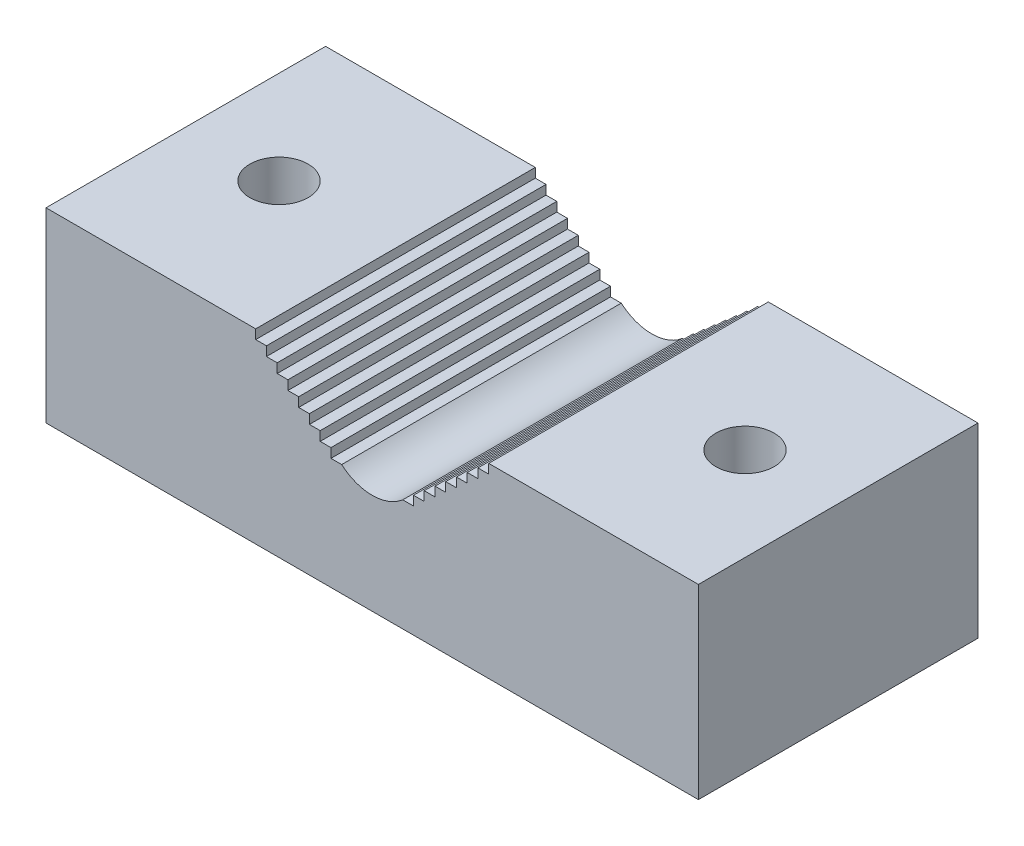
from build123d import *

# Parameters (mm, degrees)
SKETCH1_W                   = 88.9
SKETCH1_H                   = 25.4
BOSS_EXTRUDE1_DEPTH         = 38.1
CUT_EXTRUDE1_REACH          = 40.1
F_3_8_16_TAPPED_HOLE1_D     = 7.9375
F_1_4_20_TAPPED_HOLE1_D     = 5.1054
F_1_4_20_TAPPED_HOLE1_DEPTH = 16.51
F_1_4_20_TAPPED_HOLE1_TIP   = 1.533816902


with BuildPart() as part:
    # Sketch1 → Boss-Extrude1 (new body)
    with BuildSketch(Plane.XY):
        with Locations((0, 12.7)):
            Rectangle(SKETCH1_W, SKETCH1_H)
    extrude(amount=-BOSS_EXTRUDE1_DEPTH)

    # Sketch2 → Cut-Extrude1 (cut, up to next)
    with BuildSketch(Plane.XY, mode=Mode.PRIVATE) as cut_extrude1_sk1:
        with BuildLine():
            Line((-15.875, 25.4), (0, 25.4))
            Line((0, 25.4), (15.875, 25.4))
            Line((15.875, 25.4), (15.875, 24.13))
            Line((15.875, 24.13), (14.410694861, 24.13))
            Line((14.410694861, 24.13), (14.410694861, 22.86))
            Line((14.410694861, 22.86), (12.946389723, 22.86))
            Line((12.946389723, 22.86), (12.946389723, 21.59))
            Line((12.946389723, 21.59), (11.482084584, 21.59))
            Line((11.482084584, 21.59), (11.482084584, 20.32))
            Line((11.482084584, 20.32), (10.017779445, 20.32))
            Line((10.017779445, 20.32), (10.017779445, 19.05))
            Line((10.017779445, 19.05), (8.553474306, 19.05))
            Line((8.553474306, 19.05), (8.553474306, 17.78))
            Line((8.553474306, 17.78), (7.089169168, 17.78))
            Line((7.089169168, 17.78), (7.089169168, 16.51))
            Line((7.089169168, 16.51), (5.624864029, 16.51))
            Line((5.624864029, 16.51), (5.624864029, 15.24))
            Line((5.624864029, 15.24), (4.16055889, 15.24))
            ThreePointArc((4.16055889, 15.24), (0, 13.687108475), (-4.16055889, 15.24))
            Line((-4.16055889, 15.24), (-5.624864029, 15.24))
            Line((-5.624864029, 15.24), (-5.624864029, 16.51))
            Line((-5.624864029, 16.51), (-7.089169168, 16.51))
            Line((-7.089169168, 16.51), (-7.089169168, 17.78))
            Line((-7.089169168, 17.78), (-8.553474306, 17.78))
            Line((-8.553474306, 17.78), (-8.553474306, 19.05))
            Line((-8.553474306, 19.05), (-10.017779445, 19.05))
            Line((-10.017779445, 19.05), (-10.017779445, 20.32))
            Line((-10.017779445, 20.32), (-11.482084584, 20.32))
            Line((-11.482084584, 20.32), (-11.482084584, 21.59))
            Line((-11.482084584, 21.59), (-12.946389723, 21.59))
            Line((-12.946389723, 21.59), (-12.946389723, 22.86))
            Line((-12.946389723, 22.86), (-14.410694861, 22.86))
            Line((-14.410694861, 22.86), (-14.410694861, 24.13))
            Line((-14.410694861, 24.13), (-15.875, 24.13))
            Line((-15.875, 24.13), (-15.875, 25.4))
        make_face()
    cut_extrude1_tool1 = extrude(cut_extrude1_sk1.sketch, amount=-CUT_EXTRUDE1_REACH, mode=Mode.PRIVATE) & part.part
    add(cut_extrude1_tool1.solids().sort_by_distance((0, 20.970592, 0))[0], mode=Mode.SUBTRACT)

    # 3/8-16 Tapped Hole1 (through all)
    with Locations(Plane(origin=(0, 25.4, 0), x_dir=(1, 0, 0), z_dir=(0, 1, 0))):
        with Locations((-31.75, 19.05), (31.75, 19.05)):
            Hole(F_3_8_16_TAPPED_HOLE1_D / 2)

    # 1/4-20 Tapped Hole1
    with Locations(Plane(origin=(0, 0, 0), x_dir=(-1, 0, 0), z_dir=(0, -1, 0))):
        with Locations((-20.32, 19.05), (20.32, 19.05)):
            Hole(F_1_4_20_TAPPED_HOLE1_D / 2, depth=F_1_4_20_TAPPED_HOLE1_DEPTH)
            with Locations((0, 0, -(F_1_4_20_TAPPED_HOLE1_DEPTH + F_1_4_20_TAPPED_HOLE1_TIP / 2))):  # 118° drill point
                Cone(0, F_1_4_20_TAPPED_HOLE1_D / 2, F_1_4_20_TAPPED_HOLE1_TIP, mode=Mode.SUBTRACT)


solid = part.part
